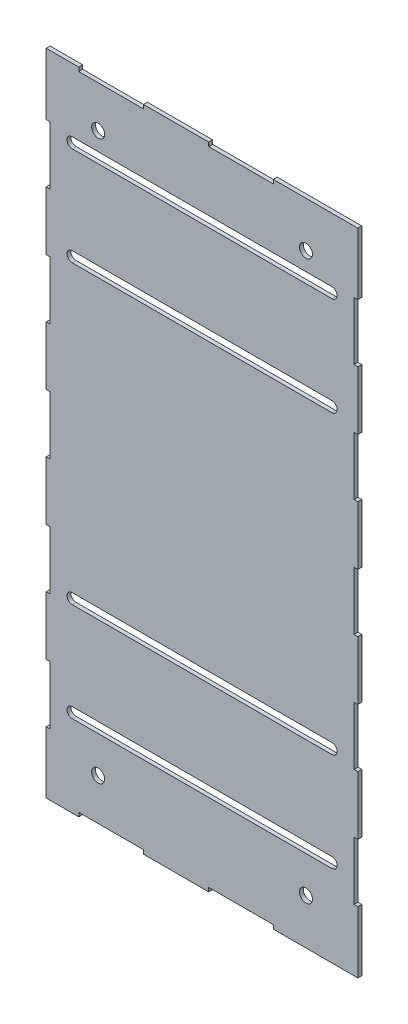
from build123d import *

# Parameters (mm, degrees)
CROQUIS1_W              = 240
CROQUIS1_H              = 500
CROQUIS1_R              = 5
SALIENTE_EXTRUIR1_DEPTH = 3
CROQUIS5_W              = 49.8
CROQUIS5_H              = 3
CROQUIS5_W_2            = 3
CROQUIS5_H_2            = 44.8
CORTAR_EXTRUIR2_DEPTH   = 4


with BuildPart() as part:
    # Croquis1 → Saliente-Extruir1 (new body)
    with BuildSketch(Plane.XY):
        Rectangle(CROQUIS1_W, CROQUIS1_H)
        with Locations((-80, -215)):
            Circle(CROQUIS1_R, mode=Mode.SUBTRACT)
        with Locations((80, -215)):
            Circle(CROQUIS1_R, mode=Mode.SUBTRACT)
        with Locations((80, 215)):
            Circle(CROQUIS1_R, mode=Mode.SUBTRACT)
        with Locations((-80, 215)):
            Circle(CROQUIS1_R, mode=Mode.SUBTRACT)
        with BuildLine():
            Line((-100, 201), (100, 201))
            ThreePointArc((100, 201), (104, 197), (100, 193))
            Line((100, 193), (-100, 193))
            ThreePointArc((-100, 193), (-104, 197), (-100, 201))
        make_face(mode=Mode.SUBTRACT)
        with BuildLine():
            Line((-100, 117), (100, 117))
            ThreePointArc((100, 117), (104, 121), (100, 125))
            Line((100, 125), (-100, 125))
            ThreePointArc((-100, 125), (-104, 121), (-100, 117))
        make_face(mode=Mode.SUBTRACT)
        with BuildLine():
            Line((-100, -111), (100, -111))
            ThreePointArc((100, -111), (104, -107), (100, -103))
            Line((100, -103), (-100, -103))
            ThreePointArc((-100, -103), (-104, -107), (-100, -111))
        make_face(mode=Mode.SUBTRACT)
        with BuildLine():
            Line((-100, -187), (100, -187))
            ThreePointArc((100, -187), (104, -183), (100, -179))
            Line((100, -179), (-100, -179))
            ThreePointArc((-100, -179), (-104, -183), (-100, -187))
        make_face(mode=Mode.SUBTRACT)
    extrude(amount=SALIENTE_EXTRUIR1_DEPTH)

    # Croquis5 → Cortar-Extruir2 (cut, through all)
    with BuildSketch(Plane(origin=(0, 0, 0), x_dir=(-1, 0, 0), z_dir=(0, 0, -1))):
        with Locations((-30, 248.5)):
            Rectangle(CROQUIS5_W, CROQUIS5_H)
        with Locations((70, 248.5)):
            Rectangle(CROQUIS5_W, CROQUIS5_H)
        with Locations((118.5, 180)):
            Rectangle(CROQUIS5_W_2, CROQUIS5_H_2)
        with Locations((118.5, 90)):
            Rectangle(CROQUIS5_W_2, CROQUIS5_H_2)
        with Locations((118.5, 0)):
            Rectangle(CROQUIS5_W_2, CROQUIS5_H_2)
        with Locations((118.5, -90)):
            Rectangle(CROQUIS5_W_2, CROQUIS5_H_2)
        with Locations((118.5, -180)):
            Rectangle(CROQUIS5_W_2, CROQUIS5_H_2)
        with Locations((70, -248.5)):
            Rectangle(CROQUIS5_W, CROQUIS5_H)
        with Locations((-30, -248.5)):
            Rectangle(CROQUIS5_W, CROQUIS5_H)
        with Locations((-118.5, -180)):
            Rectangle(CROQUIS5_W_2, CROQUIS5_H_2)
        with Locations((-118.5, -90)):
            Rectangle(CROQUIS5_W_2, CROQUIS5_H_2)
        with Locations((-118.5, 0)):
            Rectangle(CROQUIS5_W_2, CROQUIS5_H_2)
        with Locations((-118.5, 90)):
            Rectangle(CROQUIS5_W_2, CROQUIS5_H_2)
        with Locations((-118.5, 180)):
            Rectangle(CROQUIS5_W_2, CROQUIS5_H_2)
    extrude(amount=-CORTAR_EXTRUIR2_DEPTH, mode=Mode.SUBTRACT)


solid = part.part
